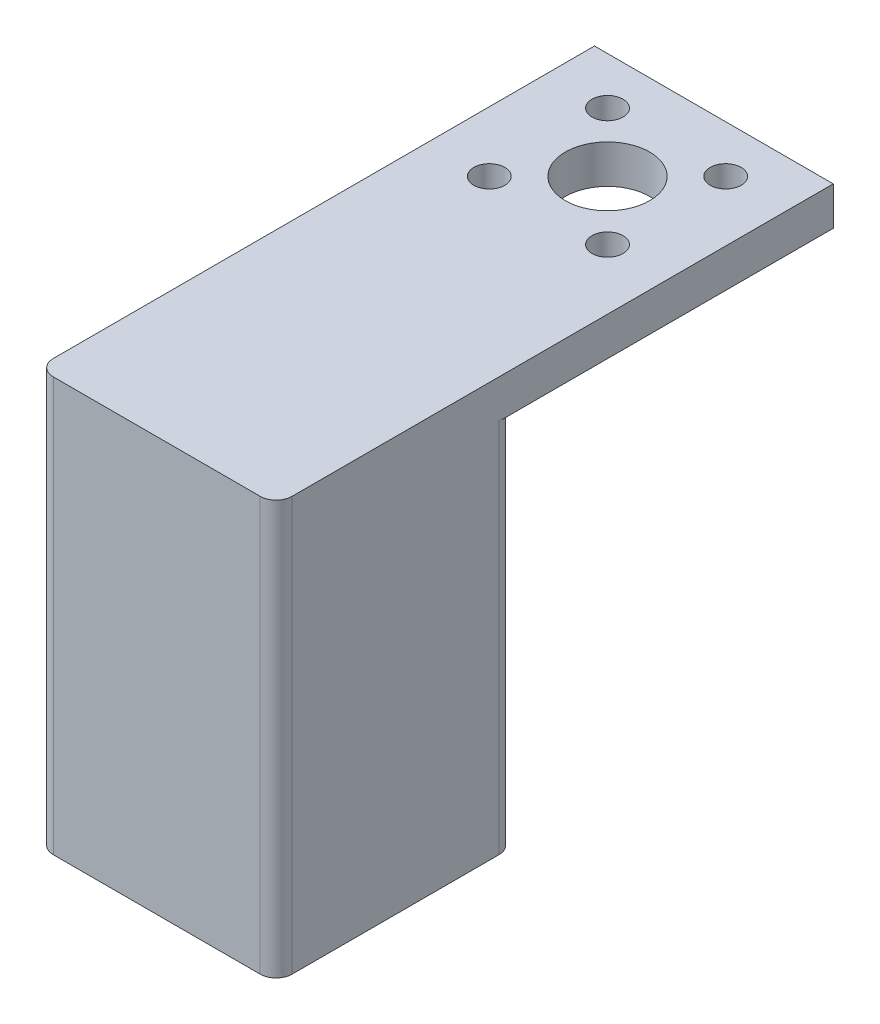
from build123d import *

# Parameters (mm, degrees)
CROQUIS1_W              = 30
CROQUIS1_H              = 30
CROQUIS1_W_2            = 24
CROQUIS1_H_2            = 24
SALIENTE_EXTRUIR1_DEPTH = 50
CROQUIS2_W              = 30
CROQUIS2_H              = 30
SALIENTE_EXTRUIR2_DEPTH = 2
CROQUIS6_W              = 30
CROQUIS6_H              = 4.83764523
SALIENTE_EXTRUIR4_DEPTH = 40
CROQUIS7_R              = 5.3
CROQUIS7_R_2            = 1.95
CORTAR_EXTRUIR2_DEPTH   = 40
REDONDEO1_R             = 2


with BuildPart() as part:
    # Croquis1 → Saliente-Extruir1 (new body)
    with BuildSketch(Plane(origin=(0, 0, 0), x_dir=(1, 0, 0), z_dir=(0, 1, 0))):
        Rectangle(CROQUIS1_W, CROQUIS1_H)
        Rectangle(CROQUIS1_W_2, CROQUIS1_H_2, mode=Mode.SUBTRACT)
    extrude(amount=SALIENTE_EXTRUIR1_DEPTH)

    # Croquis2 → Saliente-Extruir2 (add)
    with BuildSketch(Plane(origin=(0, 50, 0), x_dir=(1, 0, 0), z_dir=(0, 1, 0))):
        Rectangle(CROQUIS2_W, CROQUIS2_H)
    extrude(amount=SALIENTE_EXTRUIR2_DEPTH)

    # Croquis6 → Saliente-Extruir4 (add)
    with BuildSketch(Plane(origin=(0, 0, -15), x_dir=(-1, 0, 0), z_dir=(0, 0, -1))):
        with Locations((0, 49.581177385)):
            Rectangle(CROQUIS6_W, CROQUIS6_H)
    extrude(amount=SALIENTE_EXTRUIR4_DEPTH)

    # Croquis7 → Cortar-Extruir2 (cut)
    with BuildSketch(Plane(origin=(0, 52, 0), x_dir=(1, 0, 0), z_dir=(0, 1, 0))):
        with Locations((0, 41.634609849)):
            Circle(CROQUIS7_R)
        with Locations((7.424621202, 49.059231051)):
            Circle(CROQUIS7_R_2)
        with Locations((7.424621202, 34.209988647)):
            Circle(CROQUIS7_R_2)
        with Locations((-7.424621202, 34.209988647)):
            Circle(CROQUIS7_R_2)
        with Locations((-7.424621202, 49.059231051)):
            Circle(CROQUIS7_R_2)
    extrude(amount=-CORTAR_EXTRUIR2_DEPTH, mode=Mode.SUBTRACT)

    # Redondeo1
    redondeo1_edges = [part.edges().sort_by_distance(p)[0] for p in [
        (-15, 26, 15),
        (15, 26, 15),
        (15, 23.581177385, -15),
        (-15, 23.581177385, -15),
        (-12, 25, 12),
        (-12, 25, -12),
        (12, 25, 12),
        (12, 25, -12),
    ]]
    fillet(redondeo1_edges, radius=REDONDEO1_R)


solid = part.part
